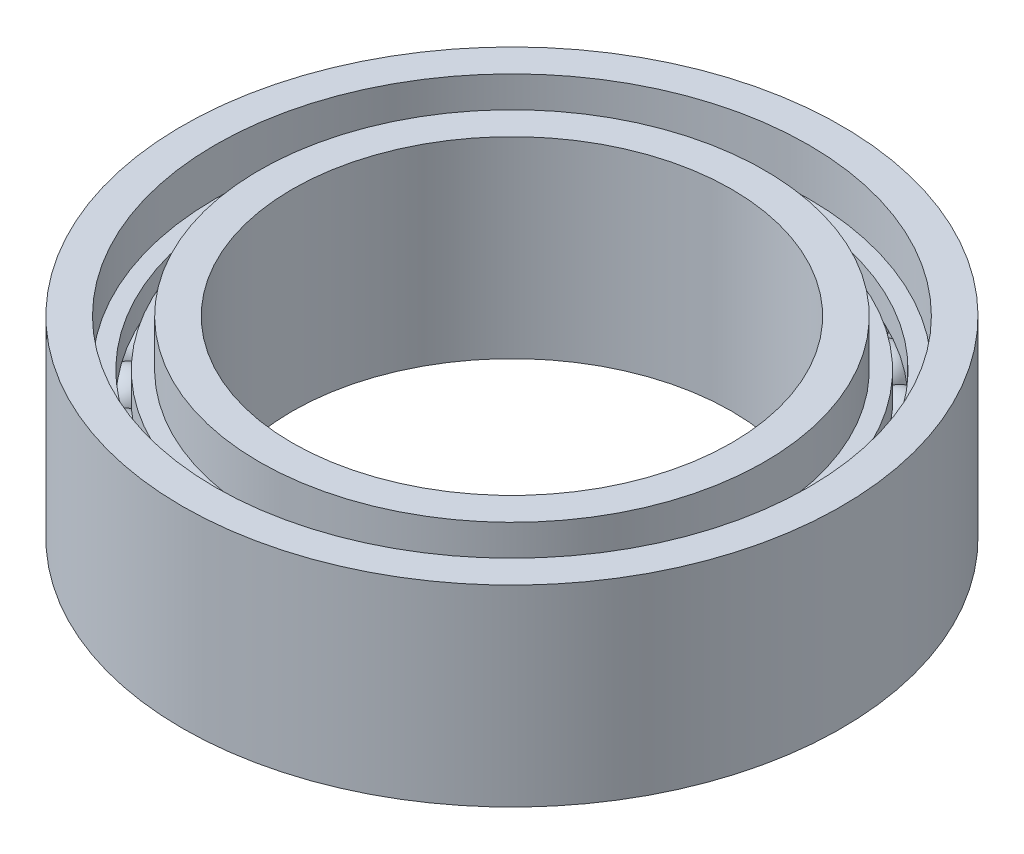
from build123d import *

# Parameters (mm, degrees)
SKETCH_1_R               = 6
SKETCH_1_R_2             = 5.4
EXTRUDE_1_DEPTH          = 3.5
SKETCH_1_R_3             = 4.6
SKETCH_1_R_4             = 4
EXTRUDE_1_2_DEPTH        = 3.5
PATTERN_CIRCULAR_7_COUNT = 30
SKETCH_4_R               = 5.4
SKETCH_4_R_2             = 5.1
SKETCH_4_R_3             = 4.9
SKETCH_4_R_4             = 4.6
EXTRUDE_2_DEPTH          = 0.5
SKETCH_6_R               = 5.4
SKETCH_6_R_2             = 5.1
SKETCH_6_R_3             = 4.9
SKETCH_6_R_4             = 4.6
EXTRUDE_4_DEPTH          = 0.5


with BuildPart() as part:
    # 스케치1 → 보스-돌출1 (new body)
    with BuildSketch(Plane(origin=(0, 0, 0), x_dir=(1, 0, 0), z_dir=(0, 1, 0))):
        Circle(SKETCH_1_R)
        Circle(SKETCH_1_R_2, mode=Mode.SUBTRACT)
    extrude(amount=EXTRUDE_1_DEPTH)



with BuildPart() as body_2:
    # 스케치1 → Extrude 1 2 (new body)
    with BuildSketch(Plane(origin=(0, 0, 0), x_dir=(1, 0, 0), z_dir=(0, 1, 0))):
        Circle(SKETCH_1_R_3)
        Circle(SKETCH_1_R_4, mode=Mode.SUBTRACT)
    extrude(amount=EXTRUDE_1_2_DEPTH)


with BuildPart() as body_3:
    # 스케치2 one side → 회전1 (revolve)
    with BuildSketch(Plane(origin=(0, 1.75, 0), x_dir=(1, 0, 0), z_dir=(0, 1, 0))):
        with BuildLine():
            ThreePointArc((-4.6, 0), (-5.000000001, 0.4), (-5.4, -2e-09))
            Line((-5.4, 0), (-4.6, 0))
        make_face()
    revolve(axis=Axis((-6.637630124, 1.75, 0), (1, 0, 0)))


with BuildPart() as pattern_circular_7_1:
    # 원형 패턴7: pattern copy
    add(body_3.part.rotate(Axis((0, 0, 0), (0, 1, 0)), 1 * 360 / PATTERN_CIRCULAR_7_COUNT))


with BuildPart() as pattern_circular_7_2:
    # 원형 패턴7: pattern copy
    add(body_3.part.rotate(Axis((0, 0, 0), (0, 1, 0)), 2 * 360 / PATTERN_CIRCULAR_7_COUNT))


with BuildPart() as pattern_circular_7_3:
    # 원형 패턴7: pattern copy
    add(body_3.part.rotate(Axis((0, 0, 0), (0, 1, 0)), 3 * 360 / PATTERN_CIRCULAR_7_COUNT))


with BuildPart() as pattern_circular_7_4:
    # 원형 패턴7: pattern copy
    add(body_3.part.rotate(Axis((0, 0, 0), (0, 1, 0)), 4 * 360 / PATTERN_CIRCULAR_7_COUNT))


with BuildPart() as pattern_circular_7_5:
    # 원형 패턴7: pattern copy
    add(body_3.part.rotate(Axis((0, 0, 0), (0, 1, 0)), 5 * 360 / PATTERN_CIRCULAR_7_COUNT))


with BuildPart() as pattern_circular_7_6:
    # 원형 패턴7: pattern copy
    add(body_3.part.rotate(Axis((0, 0, 0), (0, 1, 0)), 6 * 360 / PATTERN_CIRCULAR_7_COUNT))


with BuildPart() as pattern_circular_7_7:
    # 원형 패턴7: pattern copy
    add(body_3.part.rotate(Axis((0, 0, 0), (0, 1, 0)), 7 * 360 / PATTERN_CIRCULAR_7_COUNT))


with BuildPart() as pattern_circular_7_8:
    # 원형 패턴7: pattern copy
    add(body_3.part.rotate(Axis((0, 0, 0), (0, 1, 0)), 8 * 360 / PATTERN_CIRCULAR_7_COUNT))


with BuildPart() as pattern_circular_7_9:
    # 원형 패턴7: pattern copy
    add(body_3.part.rotate(Axis((0, 0, 0), (0, 1, 0)), 9 * 360 / PATTERN_CIRCULAR_7_COUNT))


with BuildPart() as pattern_circular_7_10:
    # 원형 패턴7: pattern copy
    add(body_3.part.rotate(Axis((0, 0, 0), (0, 1, 0)), 10 * 360 / PATTERN_CIRCULAR_7_COUNT))


with BuildPart() as pattern_circular_7_11:
    # 원형 패턴7: pattern copy
    add(body_3.part.rotate(Axis((0, 0, 0), (0, 1, 0)), 11 * 360 / PATTERN_CIRCULAR_7_COUNT))


with BuildPart() as pattern_circular_7_12:
    # 원형 패턴7: pattern copy
    add(body_3.part.rotate(Axis((0, 0, 0), (0, 1, 0)), 12 * 360 / PATTERN_CIRCULAR_7_COUNT))


with BuildPart() as pattern_circular_7_13:
    # 원형 패턴7: pattern copy
    add(body_3.part.rotate(Axis((0, 0, 0), (0, 1, 0)), 13 * 360 / PATTERN_CIRCULAR_7_COUNT))


with BuildPart() as pattern_circular_7_14:
    # 원형 패턴7: pattern copy
    add(body_3.part.rotate(Axis((0, 0, 0), (0, 1, 0)), 14 * 360 / PATTERN_CIRCULAR_7_COUNT))


with BuildPart() as pattern_circular_7_15:
    # 원형 패턴7: pattern copy
    add(body_3.part.rotate(Axis((0, 0, 0), (0, 1, 0)), 15 * 360 / PATTERN_CIRCULAR_7_COUNT))


with BuildPart() as pattern_circular_7_16:
    # 원형 패턴7: pattern copy
    add(body_3.part.rotate(Axis((0, 0, 0), (0, 1, 0)), 16 * 360 / PATTERN_CIRCULAR_7_COUNT))


with BuildPart() as pattern_circular_7_17:
    # 원형 패턴7: pattern copy
    add(body_3.part.rotate(Axis((0, 0, 0), (0, 1, 0)), 17 * 360 / PATTERN_CIRCULAR_7_COUNT))


with BuildPart() as pattern_circular_7_18:
    # 원형 패턴7: pattern copy
    add(body_3.part.rotate(Axis((0, 0, 0), (0, 1, 0)), 18 * 360 / PATTERN_CIRCULAR_7_COUNT))


with BuildPart() as pattern_circular_7_19:
    # 원형 패턴7: pattern copy
    add(body_3.part.rotate(Axis((0, 0, 0), (0, 1, 0)), 19 * 360 / PATTERN_CIRCULAR_7_COUNT))


with BuildPart() as pattern_circular_7_20:
    # 원형 패턴7: pattern copy
    add(body_3.part.rotate(Axis((0, 0, 0), (0, 1, 0)), 20 * 360 / PATTERN_CIRCULAR_7_COUNT))


with BuildPart() as pattern_circular_7_21:
    # 원형 패턴7: pattern copy
    add(body_3.part.rotate(Axis((0, 0, 0), (0, 1, 0)), 21 * 360 / PATTERN_CIRCULAR_7_COUNT))


with BuildPart() as pattern_circular_7_22:
    # 원형 패턴7: pattern copy
    add(body_3.part.rotate(Axis((0, 0, 0), (0, 1, 0)), 22 * 360 / PATTERN_CIRCULAR_7_COUNT))


with BuildPart() as pattern_circular_7_23:
    # 원형 패턴7: pattern copy
    add(body_3.part.rotate(Axis((0, 0, 0), (0, 1, 0)), 23 * 360 / PATTERN_CIRCULAR_7_COUNT))


with BuildPart() as pattern_circular_7_24:
    # 원형 패턴7: pattern copy
    add(body_3.part.rotate(Axis((0, 0, 0), (0, 1, 0)), 24 * 360 / PATTERN_CIRCULAR_7_COUNT))


with BuildPart() as pattern_circular_7_25:
    # 원형 패턴7: pattern copy
    add(body_3.part.rotate(Axis((0, 0, 0), (0, 1, 0)), 25 * 360 / PATTERN_CIRCULAR_7_COUNT))


with BuildPart() as pattern_circular_7_26:
    # 원형 패턴7: pattern copy
    add(body_3.part.rotate(Axis((0, 0, 0), (0, 1, 0)), 26 * 360 / PATTERN_CIRCULAR_7_COUNT))


with BuildPart() as pattern_circular_7_27:
    # 원형 패턴7: pattern copy
    add(body_3.part.rotate(Axis((0, 0, 0), (0, 1, 0)), 27 * 360 / PATTERN_CIRCULAR_7_COUNT))


with BuildPart() as pattern_circular_7_28:
    # 원형 패턴7: pattern copy
    add(body_3.part.rotate(Axis((0, 0, 0), (0, 1, 0)), 28 * 360 / PATTERN_CIRCULAR_7_COUNT))


with BuildPart() as pattern_circular_7_29:
    # 원형 패턴7: pattern copy
    add(body_3.part.rotate(Axis((0, 0, 0), (0, 1, 0)), 29 * 360 / PATTERN_CIRCULAR_7_COUNT))


with BuildPart() as part_1:
    add(part.part)

    add(body_2.part)  # 보스-돌출2 merges body 2
    # 스케치4 → 보스-돌출2 (add)
    with BuildSketch(Plane(origin=(0, 2.15, 0), x_dir=(1, 0, 0), z_dir=(0, 1, 0))):
        Circle(SKETCH_4_R)
        Circle(SKETCH_4_R_2, mode=Mode.SUBTRACT)
        Circle(SKETCH_4_R_3)
        Circle(SKETCH_4_R_4, mode=Mode.SUBTRACT)
    extrude(amount=EXTRUDE_2_DEPTH)

    # 스케치6 → 보스-돌출4 (add)
    with BuildSketch(Plane(origin=(0, 1.35, 0), x_dir=(-1, 0, 0), z_dir=(0, -1, 0))):
        Circle(SKETCH_6_R)
        Circle(SKETCH_6_R_2, mode=Mode.SUBTRACT)
        Circle(SKETCH_6_R_3)
        Circle(SKETCH_6_R_4, mode=Mode.SUBTRACT)
    extrude(amount=EXTRUDE_4_DEPTH)


solid = Compound([body_3.part, pattern_circular_7_1.part, pattern_circular_7_2.part, pattern_circular_7_3.part, pattern_circular_7_4.part, pattern_circular_7_5.part, pattern_circular_7_6.part, pattern_circular_7_7.part, pattern_circular_7_8.part, pattern_circular_7_9.part, pattern_circular_7_10.part, pattern_circular_7_11.part, pattern_circular_7_12.part, pattern_circular_7_13.part, pattern_circular_7_14.part, pattern_circular_7_15.part, pattern_circular_7_16.part, pattern_circular_7_17.part, pattern_circular_7_18.part, pattern_circular_7_19.part, pattern_circular_7_20.part, pattern_circular_7_21.part, pattern_circular_7_22.part, pattern_circular_7_23.part, pattern_circular_7_24.part, pattern_circular_7_25.part, pattern_circular_7_26.part, pattern_circular_7_27.part, pattern_circular_7_28.part, pattern_circular_7_29.part, part_1.part])
